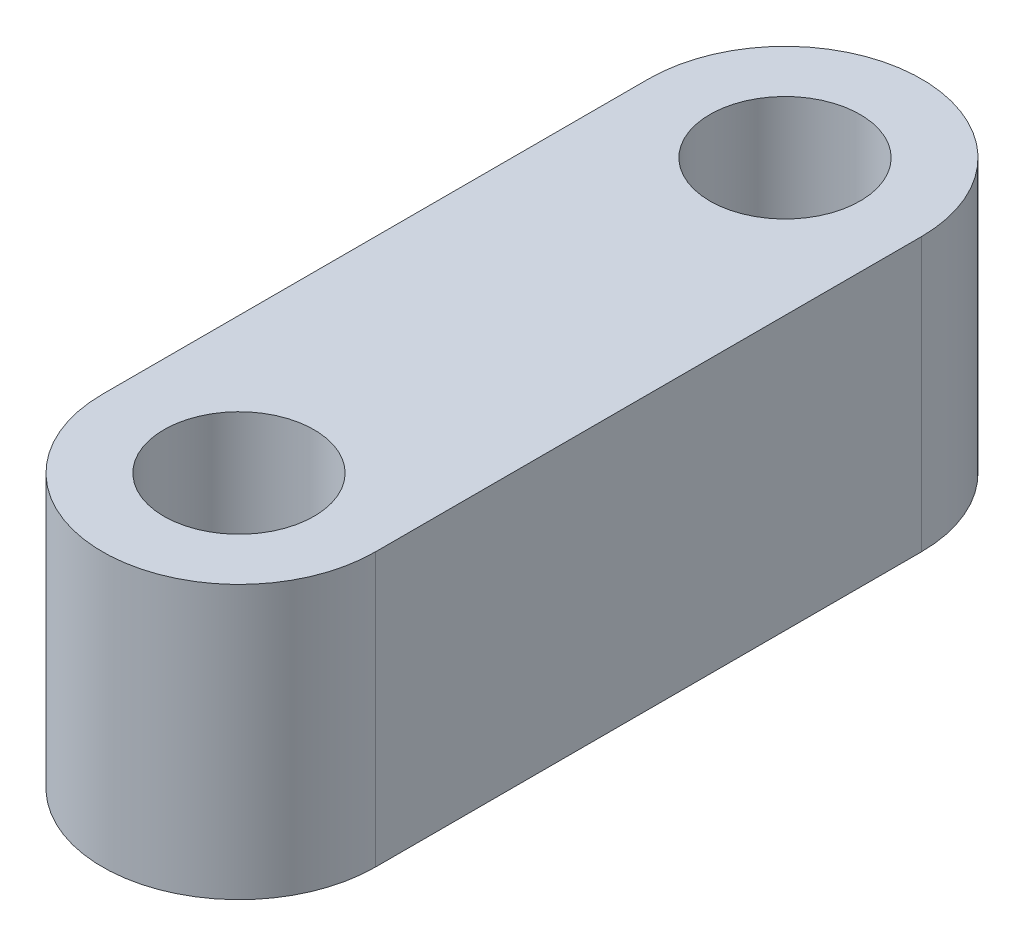
from build123d import *

# Parameters (mm, degrees)
SKETCH3_R           = 2.75
BOSS_EXTRUDE1_DEPTH = 10


with BuildPart() as part:
    # Sketch3 → Boss-Extrude1 (new body)
    with BuildSketch(Plane(origin=(0, 0, 0), x_dir=(1, 0, 0), z_dir=(0, 1, 0))):
        with BuildLine():
            ThreePointArc((-5, 0), (0, -5), (5, 0))
            Line((5, 0), (5, 20))
            ThreePointArc((5, 20), (0, 25), (-5, 20))
            Line((-5, 20), (-5, 0))
        make_face()
        Circle(SKETCH3_R, mode=Mode.SUBTRACT)
        with Locations((0, 20)):
            Circle(SKETCH3_R, mode=Mode.SUBTRACT)
    extrude(amount=BOSS_EXTRUDE1_DEPTH)


solid = part.part
